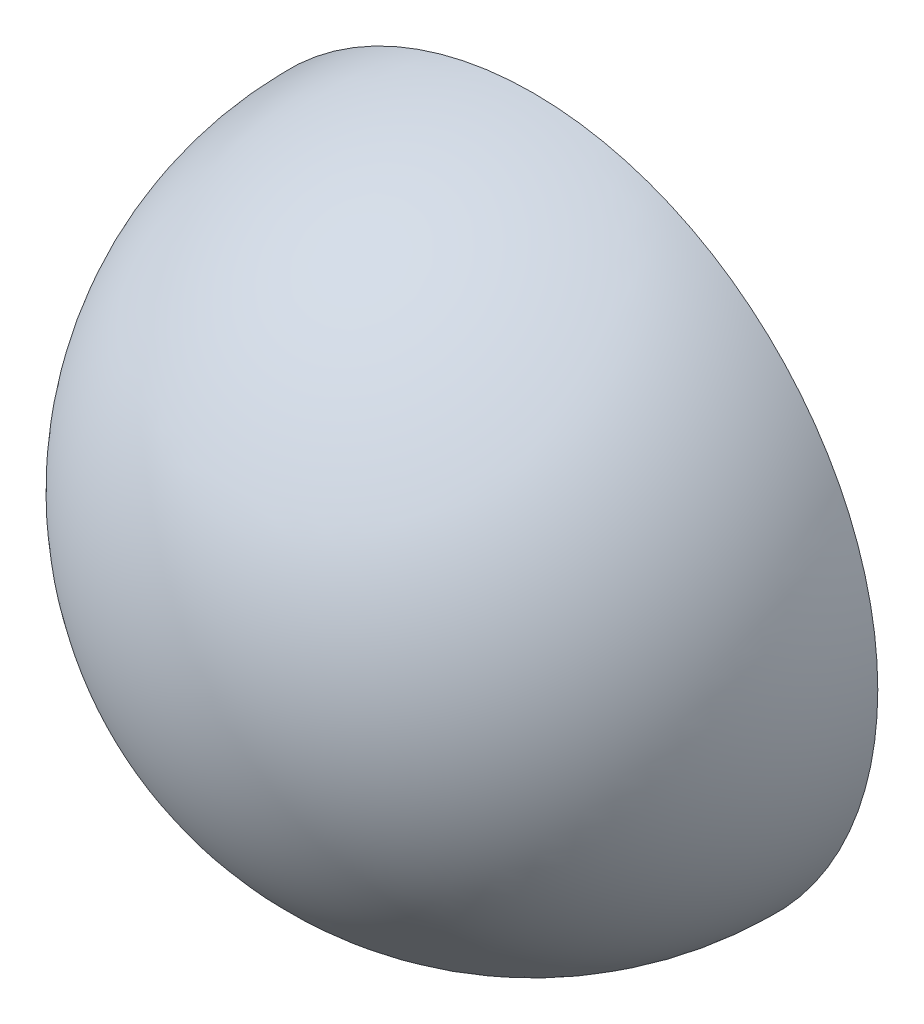
from build123d import *


with BuildPart() as part:
    # Sketch1 → Revolve1 (revolve)
    with BuildSketch(Plane(origin=(0, 0, 0), x_dir=(1, 0, 0), z_dir=(0, 1, 0))):
        with BuildLine():
            Line((-1, 0), (0, 0))
            Line((0, 0), (0, -1))
            ThreePointArc((0, -1), (-0.707106781, -0.707106781), (-1, 0))
        make_face()
    revolve(axis=Axis((0, 0, 1), (0, 0, -1)))


solid = part.part
